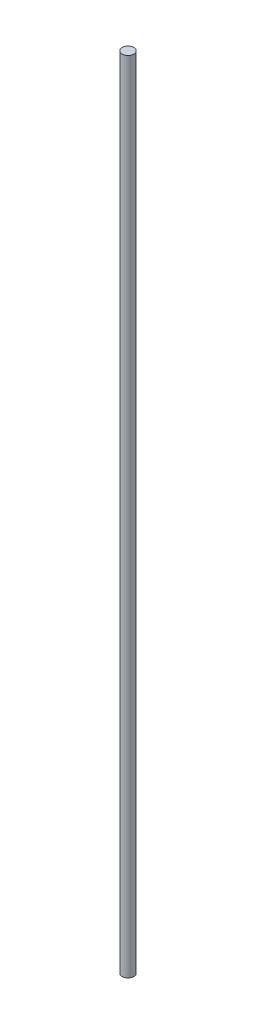
from build123d import *

# Parameters (mm, degrees)
SKETCH1_R           = 4
BOSS_EXTRUDE1_DEPTH = 550


with BuildPart() as part:
    # Sketch1 → Boss-Extrude1 (new body)
    with BuildSketch(Plane(origin=(0, 0, 0), x_dir=(1, 0, 0), z_dir=(0, 1, 0))):
        Circle(SKETCH1_R)
    extrude(amount=BOSS_EXTRUDE1_DEPTH)


solid = part.part
